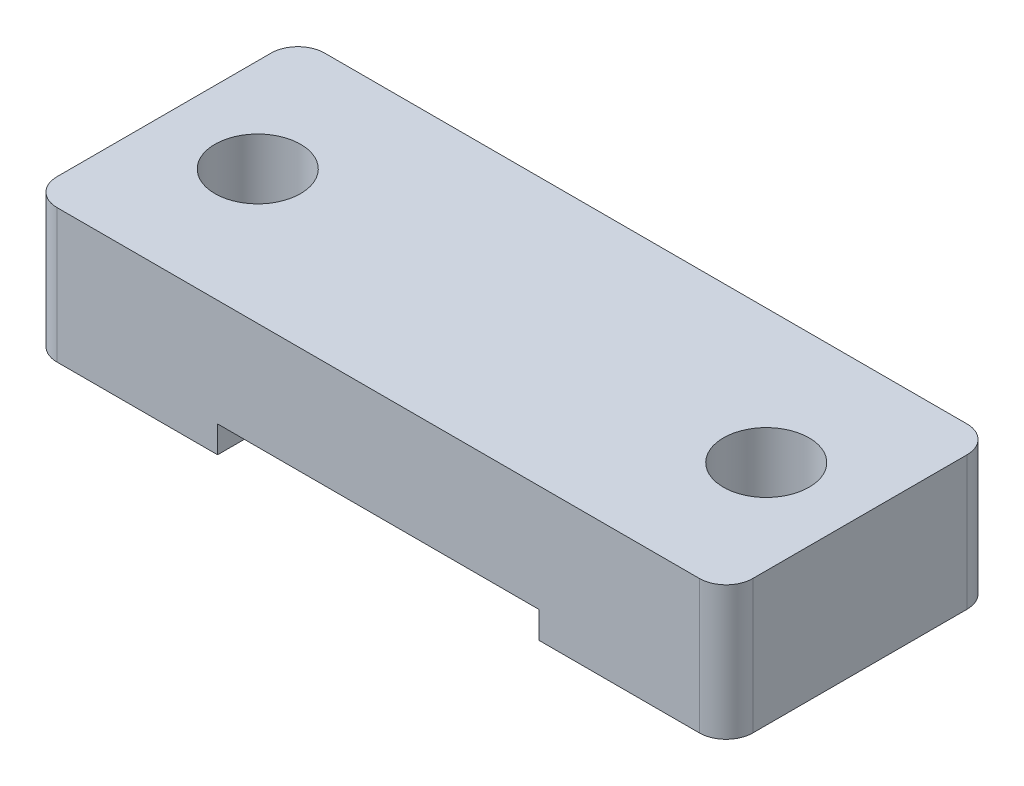
from build123d import *

# Parameters (mm, degrees)
SKETCH_2_W          = 26
SKETCH_2_H          = 10
EXTRUDE_1_DEPTH     = 4
SKETCH_3_W          = 7
SKETCH_3_H          = 10
EXTRUDE_2_DEPTH     = 1
SKETCH_4_R          = 1.6
CUT_EXTRUDE_1_DEPTH = 6
FILLET_1_R          = 1


with BuildPart() as part:
    # 草图2 → 凸台-拉伸1 (new body)
    with BuildSketch(Plane(origin=(0, 0, 0), x_dir=(1, 0, 0), z_dir=(0, 1, 0))):
        Rectangle(SKETCH_2_W, SKETCH_2_H)
    extrude(amount=EXTRUDE_1_DEPTH)

    # 草图3 → 凸台-拉伸2 (add)
    with BuildSketch(Plane.XZ):
        with Locations((9.5, 0)):
            Rectangle(SKETCH_3_W, SKETCH_3_H)
        with Locations((-9.5, 0)):
            Rectangle(SKETCH_3_W, SKETCH_3_H)
    extrude(amount=EXTRUDE_2_DEPTH)

    # 草图4 → 切除-拉伸1 (cut, through all)
    with BuildSketch(Plane.XZ.offset(1)):
        with Locations((9.5, 0)):
            Circle(SKETCH_4_R)
        with Locations((-9.5, 0)):
            Circle(SKETCH_4_R)
    extrude(amount=-CUT_EXTRUDE_1_DEPTH, mode=Mode.SUBTRACT)

    # 圆角1
    fillet_1_edges = [part.edges().sort_by_distance(p)[0] for p in [
        (13, 1.5, 5),
        (-13, 1.5, 5),
        (-13, 1.5, -5),
        (13, 1.5, -5),
    ]]
    fillet(fillet_1_edges, radius=FILLET_1_R)


solid = part.part
